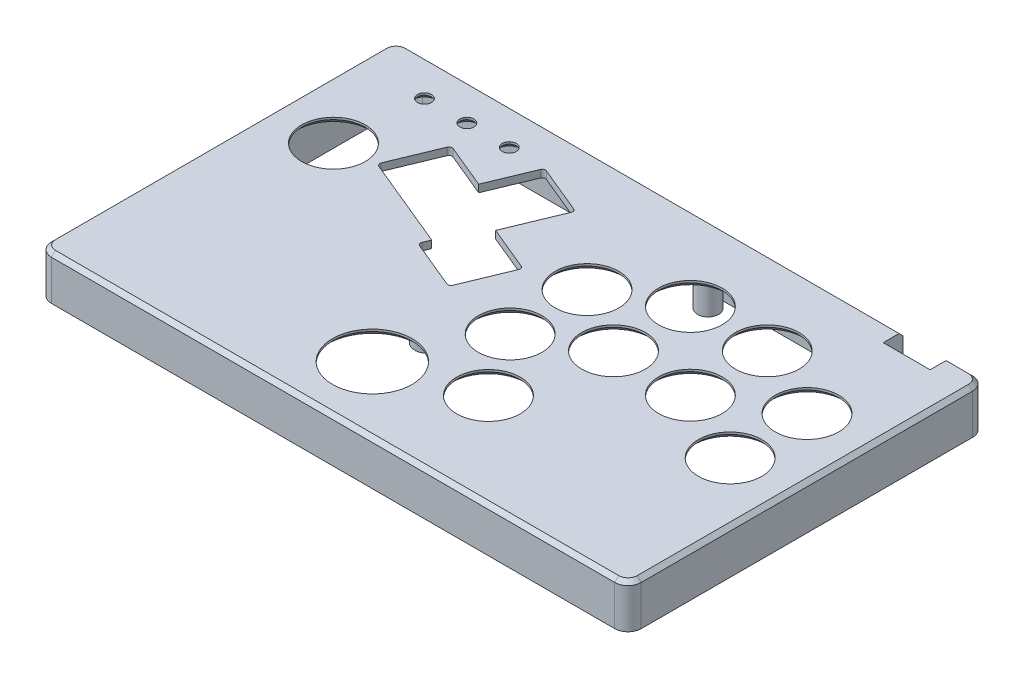
from build123d import *

# Parameters (mm, degrees)
SKETCH1_W                = 222.53
SKETCH1_H                = 135
TOP_PLATE_DEPTH          = 16.6
CORNER_FILLET_R          = 5
SKETCH4_R                = 12
SKETCH4_R_2              = 15
PRIMARY_BUTTONS_DEPTH    = 10
SKETCH8_W                = 207.53
SKETCH8_H                = 120
HOLLOW_OUT_DEPTH         = 13.8
SKETCH24_R               = 5
PCB_STANDOFF_DEPTH       = 9.8
SKETCH31_R               = 4
PCB_STANDOFF_2_DEPTH     = 12
M3_CLEARANCE_HOLE1_D     = 3.4
M3_CLEARANCE_HOLE1_DEPTH = 5.228536948
M3_CLEARANCE_HOLE1_TIP   = 1.021463052
M3_CLEARANCE_HOLE2_D     = 3.4
M3_CLEARANCE_HOLE2_DEPTH = 13.228536948
M3_CLEARANCE_HOLE2_TIP   = 1.021463052
FILLET1_R                = 10
FILLET2_R                = 5
TOP_CHAMFER_SIZE         = 1.5
NUT_START                = -8.2
NUT_CUTOUT_DEPTH         = 2
NUT_START_2              = -8
SKETCH11_3_W             = 5.8
SKETCH11_3_H             = 5.8
NUT_CUTOUT_2_DEPTH       = 2
EXTRA_BUTTONS_REACH      = 18.6
SKETCH22_R               = 2.65
HOST_USB_CUTOUT_REACH    = 9.5
SKETCH25_W               = 17.7
SKETCH25_H               = 22.9
BUTTON_CHAMFER_SIZE      = 2
USB_C_CUTOUT_REACH       = 137
SKETCH29_W               = 16
SKETCH29_H               = 1.6
SKETCH29_W_2             = 20
SKETCH29_H_2             = 4.7
CORD_RELIEF_DEPTH        = 4.1
FILLET3_R                = 2
SKETCH30_W               = 25.7
SKETCH30_H               = 5
HOST_USB_COVER_DEPTH     = 4
CHAMFER2_SIZE            = 2


with BuildPart() as part:
    # Sketch1 → Top Plate (new body)
    with BuildSketch(Plane(origin=(0, 0, 0), x_dir=(1, 0, 0), z_dir=(0, 1, 0))):
        with Locations((111.265, 67.5)):
            Rectangle(SKETCH1_W, SKETCH1_H)
    extrude(amount=TOP_PLATE_DEPTH)

    # Corner Fillet
    corner_fillet_edges = [part.edges().sort_by_distance(p)[0] for p in [
        (0, 8.3, -135),
        (222.53, 8.3, -135),
        (222.53, 8.3, 0),
        (0, 8.3, 0),
    ]]
    fillet(corner_fillet_edges, radius=CORNER_FILLET_R)

    # Sketch4 → Primary Buttons (cut)
    with BuildSketch(Plane(origin=(0, 16.6, 0), x_dir=(-1, 0, 0), z_dir=(0, -1, 0))):
        with BuildLine():
            Line((-72.617384214, 75.860635105), (-38.526229464, 89.981653759))
            ThreePointArc((-38.526229464, 89.981653759), (-37.876794144, 90.631089079), (-37.876794144, 91.549529317))
            Line((-37.876794144, 91.549529317), (-45.166913531, 109.149434411))
            ThreePointArc((-45.166913531, 109.149434411), (-45.816348851, 109.798869731), (-46.734789088, 109.798869731))
            Line((-46.734789088, 109.798869731), (-63.226038744, 102.967970464))
            Line((-63.226038744, 102.967970464), (-70.056938011, 119.459220119))
            ThreePointArc((-70.056938011, 119.459220119), (-70.706373332, 120.108655439), (-71.624813569, 120.108655439))
            Line((-71.624813569, 120.108655439), (-89.224718664, 112.818536052))
            ThreePointArc((-89.224718664, 112.818536052), (-89.874153984, 112.169100732), (-89.874153984, 111.250660495))
            Line((-89.874153984, 111.250660495), (-81.51252088, 91.063892453))
            Line((-81.51252088, 91.063892453), (-98.003770536, 84.232993185))
            ThreePointArc((-98.003770536, 84.232993185), (-98.653205856, 83.583557865), (-98.653205856, 82.665117627))
            Line((-98.653205856, 82.665117627), (-91.363086469, 65.065212533))
            ThreePointArc((-91.363086469, 65.065212533), (-90.713651149, 64.415777213), (-89.795210912, 64.415777213))
            Line((-89.795210912, 64.415777213), (-72.195305817, 71.705896599))
            ThreePointArc((-72.195305817, 71.705896599), (-71.545870497, 72.355331919), (-71.545870497, 73.273772157))
            Line((-71.545870497, 73.273772157), (-72.617384214, 75.860635105))
        make_face()
        with Locations((-22.430461824, 88.977749052)):
            Circle(SKETCH4_R)
        with Locations((-118.099538176, 59.969444892)):
            Circle(SKETCH4_R)
        with Locations((-143.099538176, 73.969444892)):
            Circle(SKETCH4_R)
        with Locations((-172.099538176, 73.969444892)):
            Circle(SKETCH4_R)
        with Locations((-172.099538176, 102.969444892)):
            Circle(SKETCH4_R)
        with Locations((-143.099538176, 102.969444892)):
            Circle(SKETCH4_R)
        with Locations((-118.099538176, 88.969444892)):
            Circle(SKETCH4_R)
        with Locations((-200.099538176, 89.969444892)):
            Circle(SKETCH4_R)
        with Locations((-200.099538176, 60.969444892)):
            Circle(SKETCH4_R)
        with Locations((-101.099538176, 24.969444892)):
            Circle(SKETCH4_R_2)
        with Locations((-134.099538176, 35.782671647)):
            Circle(SKETCH4_R)
    extrude(amount=PRIMARY_BUTTONS_DEPTH, mode=Mode.SUBTRACT)

    # Sketch8 → Hollow Out (cut)
    with BuildSketch(Plane.XZ):
        with Locations((111.265, -67.5)):
            Rectangle(SKETCH8_W, SKETCH8_H)
    extrude(amount=-HOLLOW_OUT_DEPTH, mode=Mode.SUBTRACT)

    # Sketch24 → PCB Standoff (add)
    with BuildSketch(Plane.XZ.offset(-16.6)):
        with Locations((95.620494686, -51.448398234)):
            Circle(SKETCH24_R)
        with Locations((157.599538176, -56.178884287)):
            Circle(SKETCH24_R)
        with Locations((59.675880553, -66.371354815)):
            Circle(SKETCH24_R)
    extrude(amount=PCB_STANDOFF_DEPTH)

    # Sketch31 → PCB Standoff 2 (add)
    with BuildSketch(Plane(origin=(0, 13.8, 0), x_dir=(-1, 0, 0), z_dir=(0, -1, 0))):
        with Locations((-132.265, 120.5)):
            Circle(SKETCH31_R)
        with Locations((-90.265, 120.5)):
            Circle(SKETCH31_R)
    extrude(amount=PCB_STANDOFF_2_DEPTH)

    # M3 Clearance Hole1
    with Locations(Plane(origin=(157.599538176, 6.8, -56.178884287), x_dir=(0, 0, -1), z_dir=(0, -1, 0))):
        with Locations((0, 0), (-4.730486053, -61.97904349), (10.192470528, -97.923657623)):
            Hole(M3_CLEARANCE_HOLE1_D / 2, depth=M3_CLEARANCE_HOLE1_DEPTH)
            with Locations((0, 0, -(M3_CLEARANCE_HOLE1_DEPTH + M3_CLEARANCE_HOLE1_TIP / 2))):  # 118° drill point
                Cone(0, M3_CLEARANCE_HOLE1_D / 2, M3_CLEARANCE_HOLE1_TIP, mode=Mode.SUBTRACT)

    # M3 Clearance Hole2
    with Locations(Plane(origin=(5.5, 0, -5.5), x_dir=(0, 0, -1), z_dir=(0, -1, 0))):
        with Locations((0, 0), (0, 211.53), (124, 0), (124, 211.53)):
            Hole(M3_CLEARANCE_HOLE2_D / 2, depth=M3_CLEARANCE_HOLE2_DEPTH)
            with Locations((0, 0, -(M3_CLEARANCE_HOLE2_DEPTH + M3_CLEARANCE_HOLE2_TIP / 2))):  # 118° drill point
                Cone(0, M3_CLEARANCE_HOLE2_D / 2, M3_CLEARANCE_HOLE2_TIP, mode=Mode.SUBTRACT)

    # Fillet1
    fillet1_edges = [part.edges().sort_by_distance(p)[0] for p in [
        (7.5, 6.9, -127.5),
        (7.5, 6.9, -7.5),
        (215.03, 6.9, -7.5),
    ]]
    fillet(fillet1_edges, radius=FILLET1_R)

    # Fillet2
    fillet2_edges = [part.edges().sort_by_distance(p)[0] for p in [
        (215.03, 6.9, -127.5),
    ]]
    fillet(fillet2_edges, radius=FILLET2_R)

    # Top Chamfer
    top_chamfer_edges = [part.edges().sort_by_distance(p)[0] for p in [
        (0, 16.6, -67.5),
        (111.265, 16.6, -135),
        (111.265, 16.6, 0),
        (222.53, 16.6, -67.5),
        (221.065533906, 16.6, -1.464466094),
        (221.065533906, 16.6, -133.535533906),
        (1.464466094, 16.6, -1.464466094),
        (1.464466094, 16.6, -133.535533906),
    ]]
    chamfer(top_chamfer_edges, length=TOP_CHAMFER_SIZE)

    # Sketch11 → Nut Cutout (cut)
    with BuildSketch(Plane.XZ.offset(NUT_START)):
        Polygon((217.03, -133.601219331), (212.928780669, -129.5), (217.03, -125.398780669), (221.131219331, -129.5), align=None)
        Polygon((1.398780669, -129.5), (5.5, -125.398780669), (9.601219331, -129.5), (5.5, -133.601219331), align=None)
        Polygon((5.5, -9.601219331), (1.398780669, -5.5), (5.5, -1.398780669), (9.601219331, -5.5), align=None)
        Polygon((217.03, -9.601219331), (212.928780669, -5.5), (217.03, -1.398780669), (221.131219331, -5.5), align=None)
    extrude(amount=-NUT_CUTOUT_DEPTH, mode=Mode.SUBTRACT)

    # Sketch11_3 → Nut Cutout 2 (cut)
    with BuildSketch(Plane.XZ.offset(NUT_START_2)):
        with Locations((95.620494686, -51.448398234)):
            Rectangle(SKETCH11_3_W, SKETCH11_3_H)
        with Locations((157.599538176, -56.178884287)):
            Rectangle(SKETCH11_3_W, SKETCH11_3_H)
        with Locations((59.675880553, -66.371354815)):
            Rectangle(SKETCH11_3_W, SKETCH11_3_H)
    extrude(amount=-NUT_CUTOUT_2_DEPTH, mode=Mode.SUBTRACT)

    # Sketch22 → Extra Buttons (cut, up to next)
    with BuildSketch(Plane(origin=(0, 16.6, -138.1), x_dir=(1, 0, 0), z_dir=(0, -1, 0)), mode=Mode.PRIVATE) as extra_buttons_sk1:
        with Locations((25, 17.35)):
            Circle(SKETCH22_R)
    extra_buttons_tool1 = extrude(extra_buttons_sk1.sketch, amount=EXTRA_BUTTONS_REACH, mode=Mode.PRIVATE) & part.part
    add(extra_buttons_tool1.solids().sort_by_distance((25, 16.6, -120.75))[0], mode=Mode.SUBTRACT)
    # Sketch22 → Extra Buttons (cut, up to next)
    with BuildSketch(Plane(origin=(0, 16.6, -138.1), x_dir=(1, 0, 0), z_dir=(0, -1, 0)), mode=Mode.PRIVATE) as extra_buttons_sk2:
        with Locations((41, 17.35)):
            Circle(SKETCH22_R)
    extra_buttons_tool2 = extrude(extra_buttons_sk2.sketch, amount=EXTRA_BUTTONS_REACH, mode=Mode.PRIVATE) & part.part
    add(extra_buttons_tool2.solids().sort_by_distance((41, 16.6, -120.75))[0], mode=Mode.SUBTRACT)
    # Sketch22 → Extra Buttons (cut, up to next)
    with BuildSketch(Plane(origin=(0, 16.6, -138.1), x_dir=(1, 0, 0), z_dir=(0, -1, 0)), mode=Mode.PRIVATE) as extra_buttons_sk3:
        with Locations((57, 17.35)):
            Circle(SKETCH22_R)
    extra_buttons_tool3 = extrude(extra_buttons_sk3.sketch, amount=EXTRA_BUTTONS_REACH, mode=Mode.PRIVATE) & part.part
    add(extra_buttons_tool3.solids().sort_by_distance((57, 16.6, -120.75))[0], mode=Mode.SUBTRACT)

    # Sketch25 → Host USB Cutout (cut, up to next)
    with BuildSketch(Plane.XY.offset(-127.5), mode=Mode.PRIVATE) as host_usb_cutout_sk1:
        with Locations((200.18, 11.45)):
            Rectangle(SKETCH25_W, SKETCH25_H)
    host_usb_cutout_tool1 = extrude(host_usb_cutout_sk1.sketch, amount=-HOST_USB_CUTOUT_REACH, mode=Mode.PRIVATE) & part.part
    add(host_usb_cutout_tool1.solids().sort_by_distance((200.18, 11.45, -127.5))[0], mode=Mode.SUBTRACT)

    # Button Chamfer
    button_chamfer_edges = [part.edges().sort_by_distance(p)[0] for p in [
        (212.099538176, 13.8, -60.969444892),
        (116.099538176, 13.8, -24.969444892),
        (146.099538176, 13.8, -35.782671647),
        (130.099538176, 13.8, -88.969444892),
        (184.099538176, 13.8, -102.969444892),
        (155.099538176, 13.8, -102.969444892),
        (34.430461824, 13.8, -88.977749052),
        (130.099538176, 13.8, -59.969444892),
        (155.099538176, 13.8, -73.969444892),
        (184.099538176, 13.8, -73.969444892),
        (212.099538176, 13.8, -89.969444892),
    ]]
    chamfer(button_chamfer_edges, length=BUTTON_CHAMFER_SIZE)

    # Sketch28 → USB C Cutout (cut, up to next)
    with BuildSketch(Plane(origin=(0, 0, -135), x_dir=(-1, 0, 0), z_dir=(0, 0, -1)), mode=Mode.PRIVATE) as usb_c_cutout_sk1:
        with BuildLine():
            Line((-114.265, -2), (-108.265, -2))
            ThreePointArc((-108.265, -2), (-107.204339828, -1.560660172), (-106.765, -0.5))
            Line((-106.765, -0.5), (-106.765, 0.3))
            ThreePointArc((-106.765, 0.3), (-107.204339828, 1.360660172), (-108.265, 1.8))
            Line((-108.265, 1.8), (-114.265, 1.8))
            ThreePointArc((-114.265, 1.8), (-115.325660172, 1.360660172), (-115.765, 0.3))
            Line((-115.765, 0.3), (-115.765, -0.5))
            ThreePointArc((-115.765, -0.5), (-115.325660172, -1.560660172), (-114.265, -2))
        make_face()
    usb_c_cutout_tool1 = extrude(usb_c_cutout_sk1.sketch, amount=-USB_C_CUTOUT_REACH, mode=Mode.PRIVATE) & part.part
    add(usb_c_cutout_tool1.solids().sort_by_distance((111.265, -0.1, -135))[0], mode=Mode.SUBTRACT)

    # Sketch29 → Cord Relief (cut)
    with BuildSketch(Plane.XZ):
        with Locations((111.265, -128.3)):
            Rectangle(SKETCH29_W, SKETCH29_H)
        with Locations((111.265, -132.65)):
            Rectangle(SKETCH29_W_2, SKETCH29_H_2)
    extrude(amount=-CORD_RELIEF_DEPTH, mode=Mode.SUBTRACT)

    # Fillet3
    fillet3_edges = [part.edges().sort_by_distance(p)[0] for p in [
        (121.265, 2.05, -135),
        (101.265, 2.05, -135),
    ]]
    fillet(fillet3_edges, radius=FILLET3_R)

    # Sketch30 → Host USB cover (add)
    with BuildSketch(Plane.XZ.offset(-13.8)):
        with Locations((202.18, -125)):
            Rectangle(SKETCH30_W, SKETCH30_H)
    extrude(amount=HOST_USB_COVER_DEPTH)

    # Chamfer2
    chamfer2_edges = [part.edges().sort_by_distance(p)[0] for p in [
        (22.35, 13.8, -120.75),
        (38.35, 13.8, -120.75),
        (54.35, 13.8, -120.75),
    ]]
    chamfer(chamfer2_edges, length=CHAMFER2_SIZE)


solid = part.part
